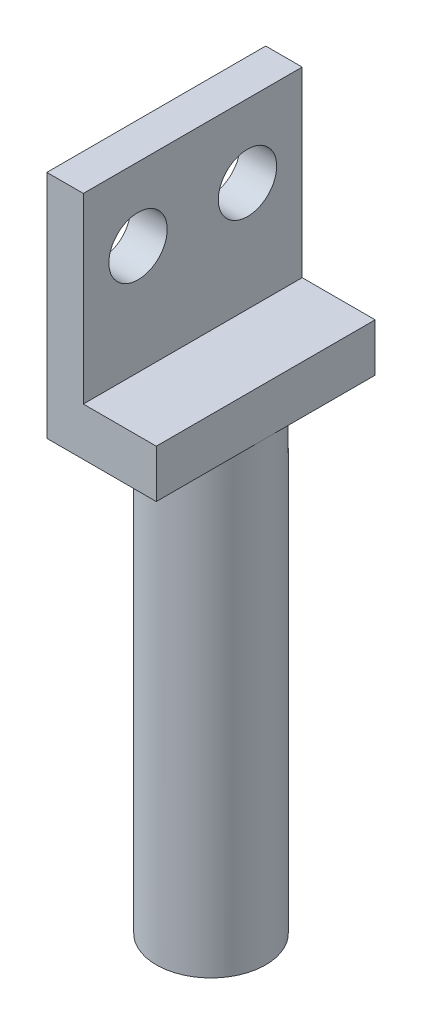
from build123d import *

# Parameters (mm, degrees)
SKETCH_1_R          = 12.25
SKETCH_1_R_2        = 1.25
EXTRUDE_1_DEPTH     = 2
SKETCH_2_R          = 3
EXTRUDE_2_DEPTH     = 10.63
SKETCH_3_W          = 2
SKETCH_3_H          = 12
EXTRUDE_3_DEPTH     = 8
SKETCH_5_R          = 1.6
CUT_EXTRUDE_1_DEPTH = 10
SKETCH_6_W          = 6
SKETCH_6_H          = 12
EXTRUDE_4_DEPTH     = 10.63
SKETCH_7_W          = 4
SKETCH_7_H          = 12
CUT_EXTRUDE_2_DEPTH = 2
SKETCH_8_R          = 12.25
CUT_EXTRUDE_3_DEPTH = 8
SKETCH_9_R          = 3
EXTRUDE_5_DEPTH     = 25


with BuildPart() as part:
    # 草图1 → 凸台-拉伸1 (new body)
    with BuildSketch(Plane(origin=(0, 0, 0), x_dir=(1, 0, 0), z_dir=(0, 1, 0))):
        Circle(SKETCH_1_R)
        with Locations((8, 0)):
            Circle(SKETCH_1_R_2, mode=Mode.SUBTRACT)
        with Locations((0, -8)):
            Circle(SKETCH_1_R_2, mode=Mode.SUBTRACT)
        with Locations((-8, 0)):
            Circle(SKETCH_1_R_2, mode=Mode.SUBTRACT)
        with Locations((0, 8)):
            Circle(SKETCH_1_R_2, mode=Mode.SUBTRACT)
    extrude(amount=EXTRUDE_1_DEPTH)

    # 草图2 → 凸台-拉伸2 (add)
    with BuildSketch(Plane(origin=(0, 2, 0), x_dir=(1, 0, 0), z_dir=(0, 1, 0))):
        Circle(SKETCH_2_R)
    extrude(amount=EXTRUDE_2_DEPTH)

    # 草图3 → 凸台-拉伸3 (add)
    with BuildSketch(Plane(origin=(0, 12.63, 0), x_dir=(1, 0, 0), z_dir=(0, 1, 0))):
        with Locations((-2, 0)):
            Rectangle(SKETCH_3_W, SKETCH_3_H)
    extrude(amount=EXTRUDE_3_DEPTH)

    # 草图5 → 切除-拉伸1 (cut)
    with BuildSketch(Plane(origin=(-1, 0, 0), x_dir=(0, 0, -1), z_dir=(1, 0, 0))):
        with Locations((3, 16.63)):
            Circle(SKETCH_5_R)
        with Locations((-3, 16.63)):
            Circle(SKETCH_5_R)
    extrude(amount=-CUT_EXTRUDE_1_DEPTH, mode=Mode.SUBTRACT)

    # 草图6 → 凸台-拉伸4 (add)
    with BuildSketch(Plane(origin=(0, 2, 0), x_dir=(1, 0, 0), z_dir=(0, 1, 0))):
        Rectangle(SKETCH_6_W, SKETCH_6_H)
    extrude(amount=EXTRUDE_4_DEPTH)

    # 草图7 → 切除-拉伸2 (cut)
    with BuildSketch(Plane(origin=(0, 12.63, 0), x_dir=(1, 0, 0), z_dir=(0, 1, 0))):
        with Locations((1, 0)):
            Rectangle(SKETCH_7_W, SKETCH_7_H)
    extrude(amount=-CUT_EXTRUDE_2_DEPTH, mode=Mode.SUBTRACT)

    # 草图8 → 切除-拉伸3 (cut)
    with BuildSketch(Plane.XZ):
        Circle(SKETCH_8_R)
    extrude(amount=-CUT_EXTRUDE_3_DEPTH, mode=Mode.SUBTRACT)

    # 草图9 → 凸台-拉伸5 (add)
    with BuildSketch(Plane.XZ.offset(-8)):
        Circle(SKETCH_9_R)
    extrude(amount=EXTRUDE_5_DEPTH)


solid = part.part
